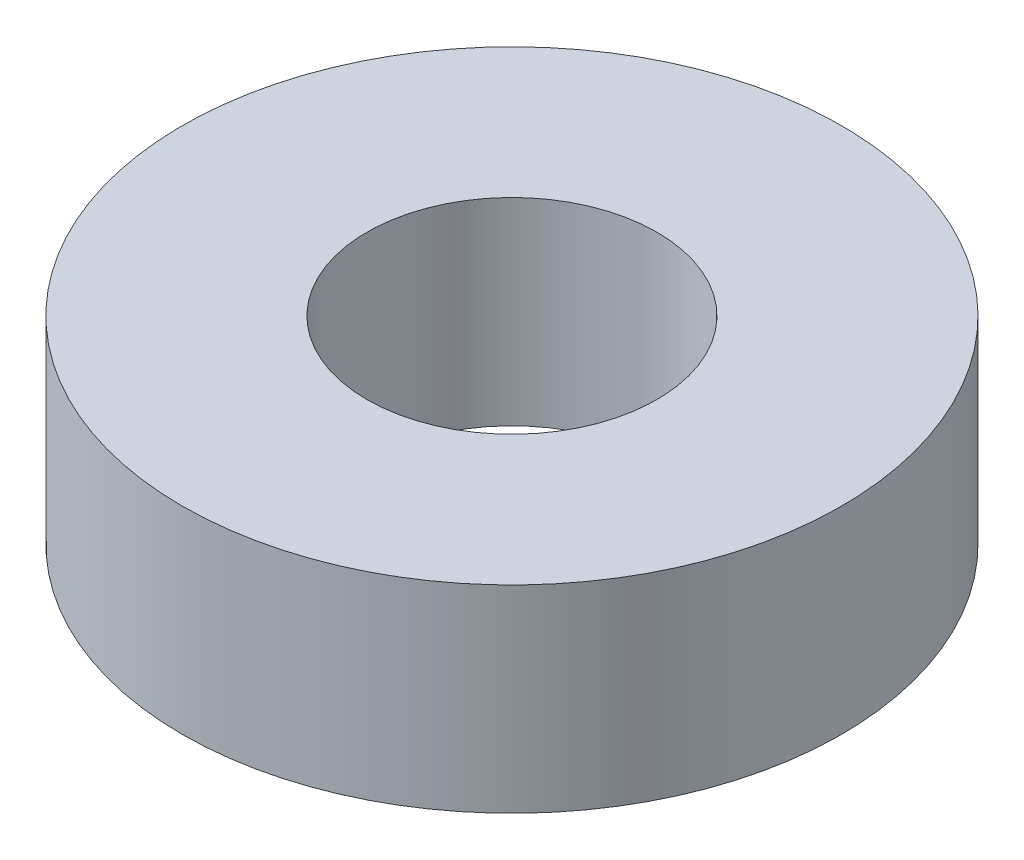
from build123d import *

# Parameters (mm, degrees)
SKETCH1_R           = 5
SKETCH1_R_2         = 2.2
BOSS_EXTRUDE1_DEPTH = 3


with BuildPart() as part:
    # Sketch1 → Boss-Extrude1 (new body)
    with BuildSketch(Plane(origin=(0, 0, 0), x_dir=(1, 0, 0), z_dir=(0, 1, 0))):
        Circle(SKETCH1_R)
        Circle(SKETCH1_R_2, mode=Mode.SUBTRACT)
    extrude(amount=BOSS_EXTRUDE1_DEPTH)


solid = part.part
